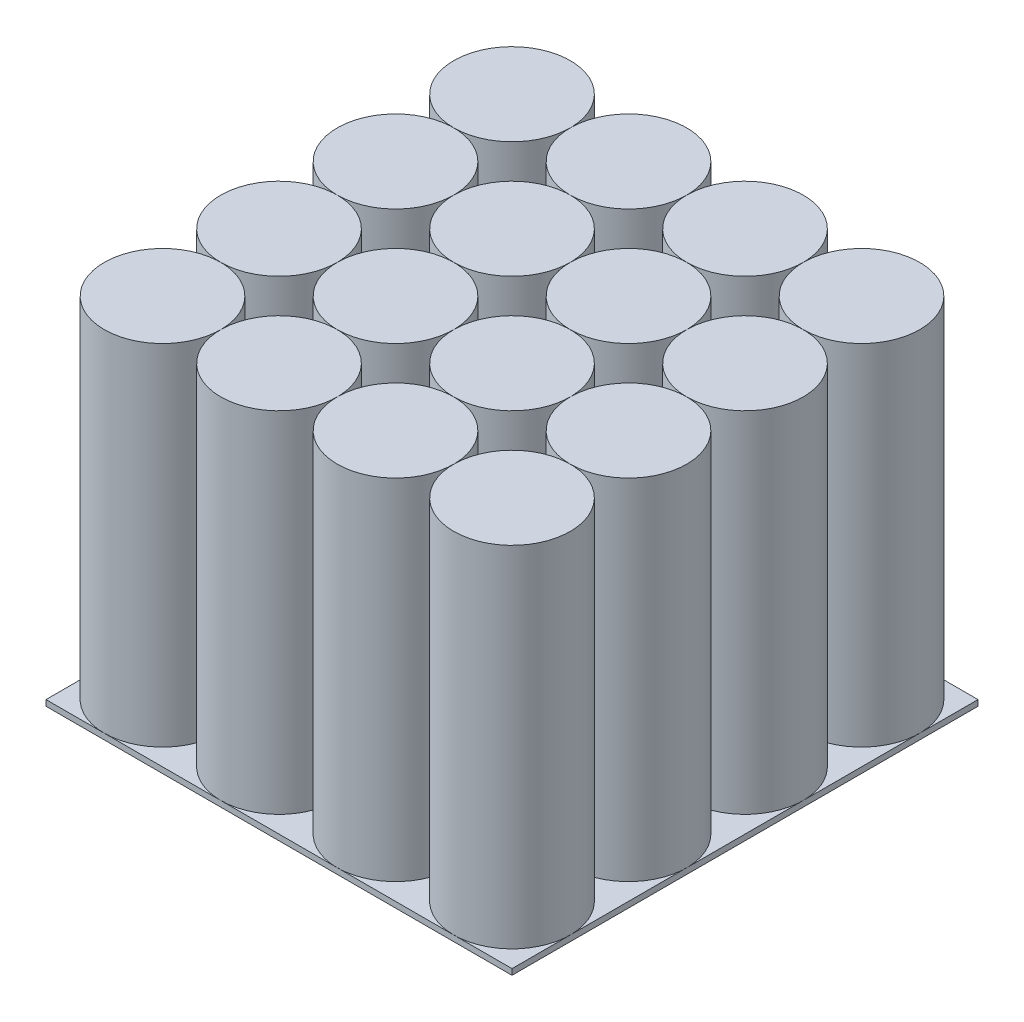
from build123d import *

# Parameters (mm, degrees)
SKETCH1_R              = 1
SKETCH1_W              = 8
SKETCH1_H              = 8
BOSS_EXTRUDE1_DEPTH    = 0.1
BOSS_EXTRUDE6_DEPTH    = 6
BOSS_EXTRUDE6_2_DEPTH  = 6
BOSS_EXTRUDE6_3_DEPTH  = 6
BOSS_EXTRUDE6_4_DEPTH  = 6
BOSS_EXTRUDE6_5_DEPTH  = 6
BOSS_EXTRUDE6_6_DEPTH  = 6
BOSS_EXTRUDE6_7_DEPTH  = 6
BOSS_EXTRUDE6_8_DEPTH  = 6
BOSS_EXTRUDE6_9_DEPTH  = 6
BOSS_EXTRUDE6_10_DEPTH = 6
BOSS_EXTRUDE6_11_DEPTH = 6
BOSS_EXTRUDE6_12_DEPTH = 6
BOSS_EXTRUDE6_13_DEPTH = 6
BOSS_EXTRUDE6_14_DEPTH = 6
BOSS_EXTRUDE6_15_DEPTH = 6
BOSS_EXTRUDE6_16_DEPTH = 6


with BuildPart() as part:
    # Sketch1 → Boss-Extrude1 (new body)
    with BuildSketch(Plane(origin=(0, 0, 0), x_dir=(1, 0, 0), z_dir=(0, 1, 0))):
        with Locations((3, 1)):
            Circle(SKETCH1_R)
        with Locations((3, 3)):
            Circle(SKETCH1_R)
        with Locations((1, 3)):
            Circle(SKETCH1_R)
        with Locations((1, 1)):
            Circle(SKETCH1_R)
        with Locations((4, 4)):
            Rectangle(SKETCH1_W, SKETCH1_H)
    extrude(amount=-BOSS_EXTRUDE1_DEPTH)


with BuildPart() as body_2:
    # Sketch1_5 → Boss-Extrude6 (new body)
    with BuildSketch(Plane(origin=(0, 0, 0), x_dir=(1, 0, 0), z_dir=(0, 1, 0))):
        with BuildLine():
            ThreePointArc((2, 1), (1.707106781, 1.707106781), (1, 2))
            ThreePointArc((1, 2), (0.292893219, 0.292893219), (2, 1))
        make_face()
    extrude(amount=BOSS_EXTRUDE6_DEPTH)


with BuildPart() as body_3:
    # Sketch1_5 → Boss-Extrude6 2 (new body)
    with BuildSketch(Plane(origin=(0, 0, 0), x_dir=(1, 0, 0), z_dir=(0, 1, 0))):
        with BuildLine():
            ThreePointArc((2, 1), (3, 0), (4, 1))
            ThreePointArc((4, 1), (3.707106781, 1.707106781), (3, 2))
            ThreePointArc((3, 2), (2.292893219, 1.707106781), (2, 1))
        make_face()
    extrude(amount=BOSS_EXTRUDE6_2_DEPTH)


with BuildPart() as body_4:
    # Sketch1_5 → Boss-Extrude6 3 (new body)
    with BuildSketch(Plane(origin=(0, 0, 0), x_dir=(1, 0, 0), z_dir=(0, 1, 0))):
        with BuildLine():
            ThreePointArc((1, 2), (1.707106781, 2.292893219), (2, 3))
            ThreePointArc((2, 3), (1.707106781, 3.707106781), (1, 4))
            ThreePointArc((1, 4), (0, 3), (1, 2))
        make_face()
    extrude(amount=BOSS_EXTRUDE6_3_DEPTH)


with BuildPart() as body_5:
    # Sketch1_5 → Boss-Extrude6 4 (new body)
    with BuildSketch(Plane(origin=(0, 0, 0), x_dir=(1, 0, 0), z_dir=(0, 1, 0))):
        with BuildLine():
            ThreePointArc((4, 1), (5, 0), (6, 1))
            ThreePointArc((6, 1), (5.707106781, 1.707106781), (5, 2))
            ThreePointArc((5, 2), (4.292893219, 1.707106781), (4, 1))
        make_face()
    extrude(amount=BOSS_EXTRUDE6_4_DEPTH)


with BuildPart() as body_6:
    # Sketch1_5 → Boss-Extrude6 5 (new body)
    with BuildSketch(Plane(origin=(0, 0, 0), x_dir=(1, 0, 0), z_dir=(0, 1, 0))):
        with BuildLine():
            ThreePointArc((2, 3), (2.292893219, 2.292893219), (3, 2))
            ThreePointArc((3, 2), (3.707106781, 2.292893219), (4, 3))
            ThreePointArc((4, 3), (3.707106781, 3.707106781), (3, 4))
            ThreePointArc((3, 4), (2.292893219, 3.707106781), (2, 3))
        make_face()
    extrude(amount=BOSS_EXTRUDE6_5_DEPTH)


with BuildPart() as body_7:
    # Sketch1_5 → Boss-Extrude6 6 (new body)
    with BuildSketch(Plane(origin=(0, 0, 0), x_dir=(1, 0, 0), z_dir=(0, 1, 0))):
        with BuildLine():
            ThreePointArc((1, 4), (1.707106781, 4.292893219), (2, 5))
            ThreePointArc((2, 5), (1.707106781, 5.707106781), (1, 6))
            ThreePointArc((1, 6), (0, 5), (1, 4))
        make_face()
    extrude(amount=BOSS_EXTRUDE6_6_DEPTH)


with BuildPart() as body_8:
    # Sketch1_5 → Boss-Extrude6 7 (new body)
    with BuildSketch(Plane(origin=(0, 0, 0), x_dir=(1, 0, 0), z_dir=(0, 1, 0))):
        with BuildLine():
            ThreePointArc((6, 1), (7.707106781, 0.292893219), (7, 2))
            ThreePointArc((7, 2), (6.292893219, 1.707106781), (6, 1))
        make_face()
    extrude(amount=BOSS_EXTRUDE6_7_DEPTH)


with BuildPart() as body_9:
    # Sketch1_5 → Boss-Extrude6 8 (new body)
    with BuildSketch(Plane(origin=(0, 0, 0), x_dir=(1, 0, 0), z_dir=(0, 1, 0))):
        with BuildLine():
            ThreePointArc((4, 3), (4.292893219, 2.292893219), (5, 2))
            ThreePointArc((5, 2), (5.707106781, 2.292893219), (6, 3))
            ThreePointArc((6, 3), (5.707106781, 3.707106781), (5, 4))
            ThreePointArc((5, 4), (4.292893219, 3.707106781), (4, 3))
        make_face()
    extrude(amount=BOSS_EXTRUDE6_8_DEPTH)


with BuildPart() as body_10:
    # Sketch1_5 → Boss-Extrude6 9 (new body)
    with BuildSketch(Plane(origin=(0, 0, 0), x_dir=(1, 0, 0), z_dir=(0, 1, 0))):
        with BuildLine():
            ThreePointArc((1, 6), (1.707106781, 6.292893219), (2, 7))
            ThreePointArc((2, 7), (0.292893219, 7.707106781), (1, 6))
        make_face()
    extrude(amount=BOSS_EXTRUDE6_9_DEPTH)


with BuildPart() as body_11:
    # Sketch1_5 → Boss-Extrude6 10 (new body)
    with BuildSketch(Plane(origin=(0, 0, 0), x_dir=(1, 0, 0), z_dir=(0, 1, 0))):
        with BuildLine():
            ThreePointArc((3, 4), (3.707106781, 4.292893219), (4, 5))
            ThreePointArc((4, 5), (3.707106781, 5.707106781), (3, 6))
            ThreePointArc((3, 6), (2.292893219, 5.707106781), (2, 5))
            ThreePointArc((2, 5), (2.292893219, 4.292893219), (3, 4))
        make_face()
    extrude(amount=BOSS_EXTRUDE6_10_DEPTH)


with BuildPart() as body_12:
    # Sketch1_5 → Boss-Extrude6 11 (new body)
    with BuildSketch(Plane(origin=(0, 0, 0), x_dir=(1, 0, 0), z_dir=(0, 1, 0))):
        with BuildLine():
            ThreePointArc((6, 3), (6.292893219, 2.292893219), (7, 2))
            ThreePointArc((7, 2), (8, 3), (7, 4))
            ThreePointArc((7, 4), (6.292893219, 3.707106781), (6, 3))
        make_face()
    extrude(amount=BOSS_EXTRUDE6_11_DEPTH)


with BuildPart() as body_13:
    # Sketch1_5 → Boss-Extrude6 12 (new body)
    with BuildSketch(Plane(origin=(0, 0, 0), x_dir=(1, 0, 0), z_dir=(0, 1, 0))):
        with BuildLine():
            ThreePointArc((4, 5), (4.292893219, 4.292893219), (5, 4))
            ThreePointArc((5, 4), (5.707106781, 4.292893219), (6, 5))
            ThreePointArc((6, 5), (5.707106781, 5.707106781), (5, 6))
            ThreePointArc((5, 6), (4.292893219, 5.707106781), (4, 5))
        make_face()
    extrude(amount=BOSS_EXTRUDE6_12_DEPTH)


with BuildPart() as body_14:
    # Sketch1_5 → Boss-Extrude6 13 (new body)
    with BuildSketch(Plane(origin=(0, 0, 0), x_dir=(1, 0, 0), z_dir=(0, 1, 0))):
        with BuildLine():
            ThreePointArc((3, 6), (3.707106781, 6.292893219), (4, 7))
            ThreePointArc((4, 7), (3, 8), (2, 7))
            ThreePointArc((2, 7), (2.292893219, 6.292893219), (3, 6))
        make_face()
    extrude(amount=BOSS_EXTRUDE6_13_DEPTH)


with BuildPart() as body_15:
    # Sketch1_5 → Boss-Extrude6 14 (new body)
    with BuildSketch(Plane(origin=(0, 0, 0), x_dir=(1, 0, 0), z_dir=(0, 1, 0))):
        with BuildLine():
            ThreePointArc((6, 5), (6.292893219, 4.292893219), (7, 4))
            ThreePointArc((7, 4), (8, 5), (7, 6))
            ThreePointArc((7, 6), (6.292893219, 5.707106781), (6, 5))
        make_face()
    extrude(amount=BOSS_EXTRUDE6_14_DEPTH)


with BuildPart() as body_16:
    # Sketch1_5 → Boss-Extrude6 15 (new body)
    with BuildSketch(Plane(origin=(0, 0, 0), x_dir=(1, 0, 0), z_dir=(0, 1, 0))):
        with BuildLine():
            ThreePointArc((5, 6), (5.707106781, 6.292893219), (6, 7))
            ThreePointArc((6, 7), (5, 8), (4, 7))
            ThreePointArc((4, 7), (4.292893219, 6.292893219), (5, 6))
        make_face()
    extrude(amount=BOSS_EXTRUDE6_15_DEPTH)


with BuildPart() as body_17:
    # Sketch1_5 → Boss-Extrude6 16 (new body)
    with BuildSketch(Plane(origin=(0, 0, 0), x_dir=(1, 0, 0), z_dir=(0, 1, 0))):
        with BuildLine():
            ThreePointArc((6, 7), (6.292893219, 6.292893219), (7, 6))
            ThreePointArc((7, 6), (7.707106781, 7.707106781), (6, 7))
        make_face()
    extrude(amount=BOSS_EXTRUDE6_16_DEPTH)


solid = Compound([part.part, body_2.part, body_3.part, body_4.part, body_5.part, body_6.part, body_7.part, body_8.part, body_9.part, body_10.part, body_11.part, body_12.part, body_13.part, body_14.part, body_15.part, body_16.part, body_17.part])
